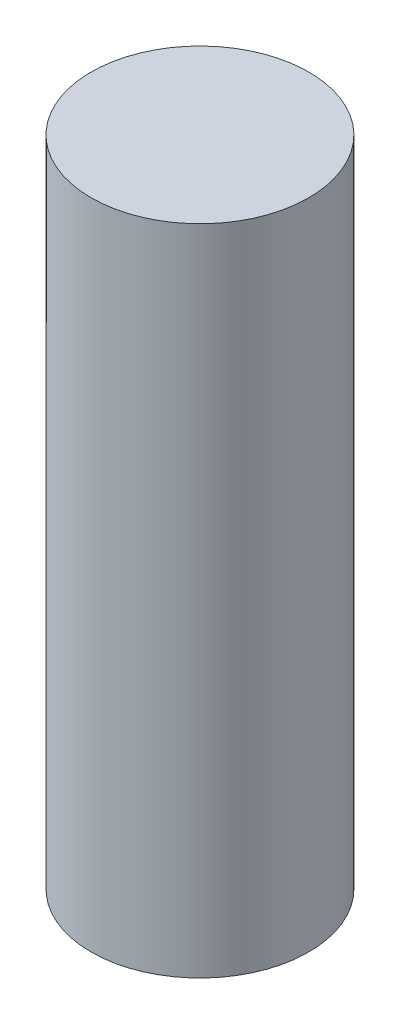
from build123d import *

# Parameters (mm, degrees)
SKETCH1_R           = 1.25
BOSS_EXTRUDE1_DEPTH = 7.5


with BuildPart() as part:
    # Sketch1 → Boss-Extrude1 (new body)
    with BuildSketch(Plane(origin=(0, 0, 0), x_dir=(1, 0, 0), z_dir=(0, 1, 0))):
        Circle(SKETCH1_R)
    extrude(amount=BOSS_EXTRUDE1_DEPTH)


solid = part.part
